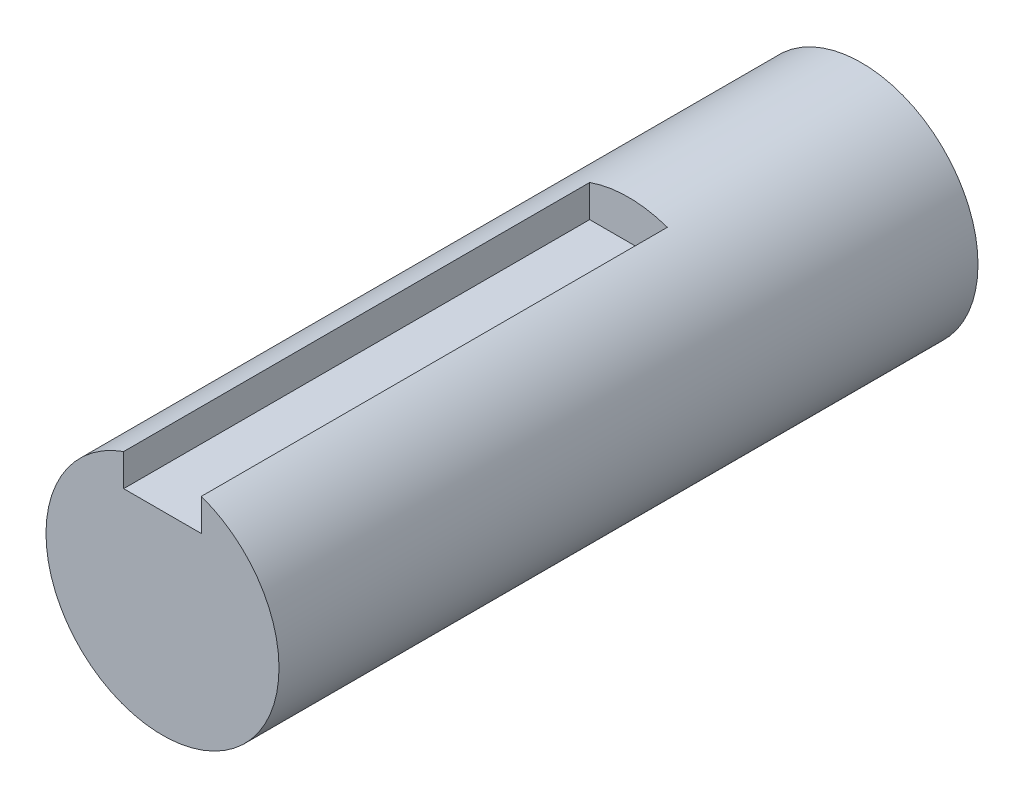
from build123d import *

# Parameters (mm, degrees)
SKETCH1_R           = 7.5
BOSS_EXTRUDE1_DEPTH = 45
SKETCH2_W           = 5
SKETCH2_H           = 4.459975541
CUT_EXTRUDE1_DEPTH  = 30


with BuildPart() as part:
    # Sketch1 → Boss-Extrude1 (new body)
    with BuildSketch(Plane.XY):
        Circle(SKETCH1_R)
    extrude(amount=BOSS_EXTRUDE1_DEPTH)

    # Sketch2 → Cut-Extrude1 (cut)
    with BuildSketch(Plane.XY.offset(45)):
        with Locations((0, 7.229987771)):
            Rectangle(SKETCH2_W, SKETCH2_H)
    extrude(amount=-CUT_EXTRUDE1_DEPTH, mode=Mode.SUBTRACT)


solid = part.part
